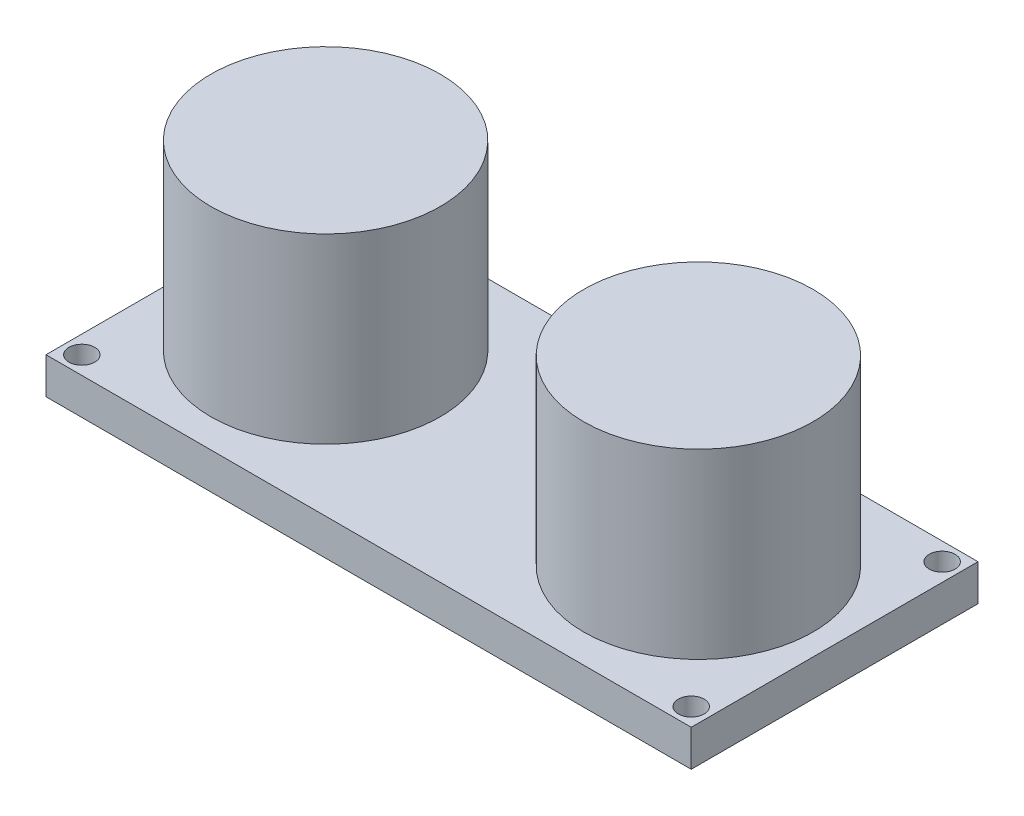
from build123d import *

# Parameters (mm, degrees)
SKETCH2_W              = 45
SKETCH2_H              = 20
BOSS_EXTRUDE1_DEPTH    = 2.54
M1_6_CLEARANCE_HOLE1_D = 1.8
SKETCH6_R              = 8
BOSS_EXTRUDE2_DEPTH    = 12.7


with BuildPart() as part:
    # Sketch2 → Boss-Extrude1 (new body)
    with BuildSketch(Plane(origin=(0, 0, 0), x_dir=(1, 0, 0), z_dir=(0, 1, 0))):
        with Locations((22.5, 10)):
            Rectangle(SKETCH2_W, SKETCH2_H)
    extrude(amount=BOSS_EXTRUDE1_DEPTH)

    # M1.6 Clearance Hole1 (through all)
    with Locations(Plane(origin=(0, 2.54, 0), x_dir=(1, 0, 0), z_dir=(0, 1, 0))):
        with Locations((43.75, 18.75), (1.25, 18.75), (1.25, 1.25), (43.75, 1.25)):
            Hole(M1_6_CLEARANCE_HOLE1_D / 2)

    # Sketch6 → Boss-Extrude2 (add)
    with BuildSketch(Plane(origin=(0, 2.54, 0), x_dir=(1, 0, 0), z_dir=(0, 1, 0))):
        with Locations((9.5, 10)):
            Circle(SKETCH6_R)
        with Locations((35.5, 10)):
            Circle(SKETCH6_R)
    extrude(amount=BOSS_EXTRUDE2_DEPTH)


solid = part.part
